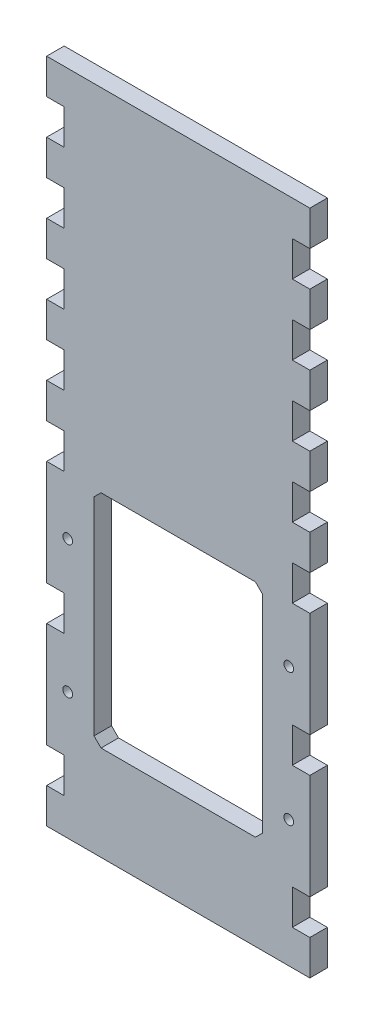
from build123d import *

# Parameters (mm, degrees)
SKETCH1_W           = 95.25
SKETCH1_H           = 241.3
BOSS_EXTRUDE1_DEPTH = 6.35
SKETCH2_W           = 6.35
SKETCH2_H           = 12.7
CUT_EXTRUDE1_DEPTH  = 7.35
LPATTERN1_COUNT     = 9
LPATTERN1_PITCH     = 25.4
SKETCH3_R           = 1.75
CUT_EXTRUDE2_DEPTH  = 7.35
SKETCH4_W           = 60.96
SKETCH4_H           = 80.01
CUT_EXTRUDE3_DEPTH  = 7.35
CHAMFER1_SIZE       = 2.54


with BuildPart() as part:
    # Sketch1 → Boss-Extrude1 (new body)
    with BuildSketch(Plane.XY):
        with Locations((47.625, 120.65)):
            Rectangle(SKETCH1_W, SKETCH1_H)
    extrude(amount=BOSS_EXTRUDE1_DEPTH)

    # Sketch2 → Cut-Extrude1 (cut, through all)
    with BuildSketch(Plane.XY.offset(6.35)):
        with Locations((3.175, 222.25)):
            Rectangle(SKETCH2_W, SKETCH2_H)
        with Locations((92.075, 222.25)):
            Rectangle(SKETCH2_W, SKETCH2_H)
    cut_extrude1 = extrude(amount=-CUT_EXTRUDE1_DEPTH, mode=Mode.SUBTRACT)

    # LPattern1: Cut-Extrude1 ×9, 2 skipped
    with Locations(*[(0, -i * LPATTERN1_PITCH, 0) for i in range(1, LPATTERN1_COUNT) if i not in (5, 7)]):
        add(cut_extrude1, mode=Mode.SUBTRACT)

    # Sketch3 → Cut-Extrude2 (cut, through all)
    with BuildSketch(Plane.XY.offset(6.35)):
        with Locations((7.625, 93.85)):
            Circle(SKETCH3_R)
        with Locations((7.625, 45.85)):
            Circle(SKETCH3_R)
        with Locations((87.625, 93.85)):
            Circle(SKETCH3_R)
        with Locations((87.625, 45.85)):
            Circle(SKETCH3_R)
    extrude(amount=-CUT_EXTRUDE2_DEPTH, mode=Mode.SUBTRACT)

    # Sketch4 → Cut-Extrude3 (cut, through all)
    with BuildSketch(Plane.XY.offset(6.35)):
        with Locations((47.625, 74.295)):
            Rectangle(SKETCH4_W, SKETCH4_H)
    extrude(amount=-CUT_EXTRUDE3_DEPTH, mode=Mode.SUBTRACT)

    # Chamfer1
    chamfer1_edges = [part.edges().sort_by_distance(p)[0] for p in [
        (17.145, 114.3, 3.175),
        (78.105, 114.3, 3.175),
        (78.105, 34.29, 3.175),
        (17.145, 34.29, 3.175),
    ]]
    chamfer(chamfer1_edges, length=CHAMFER1_SIZE)


solid = part.part
